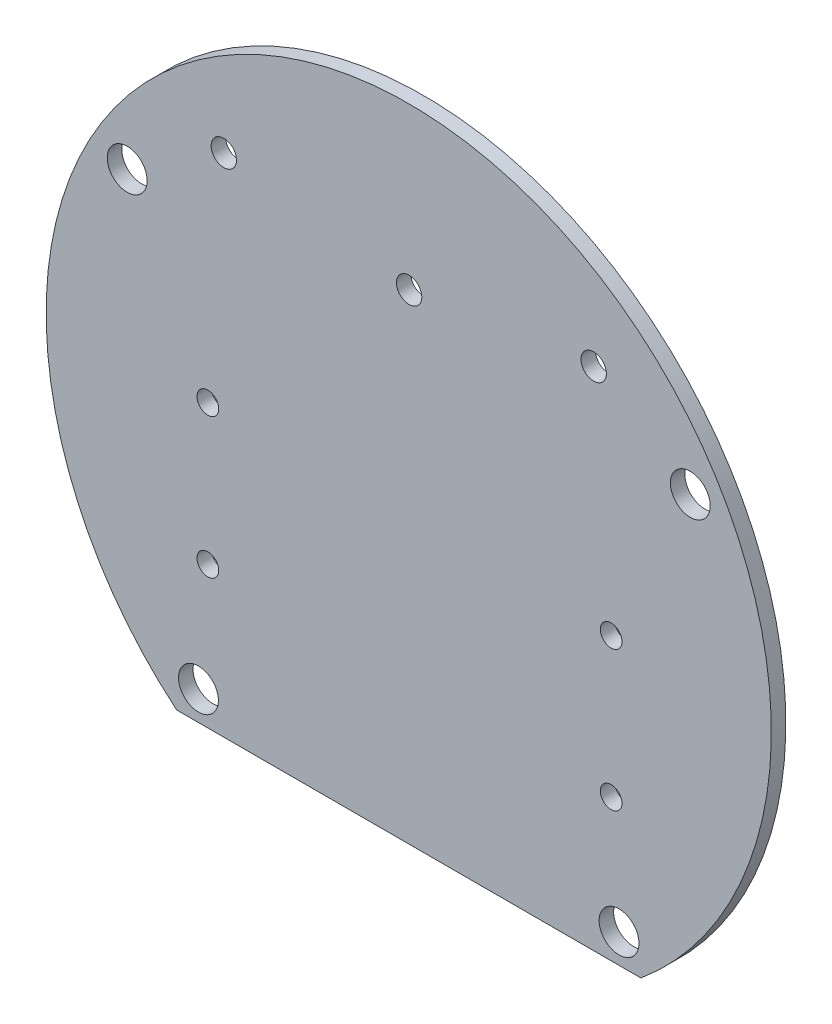
from build123d import *

# Parameters (mm, degrees)
ESBO_O1_R                  = 50
RESSALTO_EXTRUS_O1_DEPTH   = 2
ESBO_O2_R                  = 2.75
CORTE_EXTRUS_O1_DEPTH      = 2
CORTE_EXTRUS_O2_DEPTH      = 1
CORTE_EXTRUS_O2_DEPTH_BACK = 10
ESBO_O5_R                  = 1.5
ESBO_O5_R_2                = 1.75
CORTE_EXTRUS_O3_DEPTH      = 10


with BuildPart() as part:
    # Esboço1 → Ressalto-extrusão1 (new body)
    with BuildSketch(Plane.XY):
        Circle(ESBO_O1_R)
    extrude(amount=RESSALTO_EXTRUS_O1_DEPTH)

    # Esboço2 → Corte-extrusão1 (cut)
    with BuildSketch(Plane.XY.offset(2)):
        with Locations((-29, -34.409301068)):
            Circle(ESBO_O2_R)
        with Locations((29, -34.409301068)):
            Circle(ESBO_O2_R)
        with Locations((-38.824197531, 22.752619324)):
            Circle(ESBO_O2_R)
        with Locations((38.824197531, 22.752619324)):
            Circle(ESBO_O2_R)
    extrude(amount=-CORTE_EXTRUS_O1_DEPTH, mode=Mode.SUBTRACT)

    # Esboço4 → Corte-extrusão2 (cut, two sides)
    with BuildSketch(Plane.XY.offset(2)) as corte_extrus_o2_sk:
        Polygon((-40.723859979, -38.409301068), (44.57073926, -38.409301068), (1.923439641, -68.002213614), align=None)
    extrude(amount=CORTE_EXTRUS_O2_DEPTH, mode=Mode.SUBTRACT)
    extrude(corte_extrus_o2_sk.sketch, amount=-CORTE_EXTRUS_O2_DEPTH_BACK, mode=Mode.SUBTRACT)

    # Esboço5 → Corte-extrusão3 (cut)
    with BuildSketch(Plane(origin=(0, 0, 0), x_dir=(-1, 0, 0), z_dir=(0, 0, -1))):
        with Locations((-27.91, -18.86)):
            Circle(ESBO_O5_R)
        with Locations((27.7, -18.86)):
            Circle(ESBO_O5_R)
        with Locations((27.7, 0.44)):
            Circle(ESBO_O5_R)
        with Locations((-27.91, 0.44)):
            Circle(ESBO_O5_R)
        with Locations((25.5, 31.36)):
            Circle(ESBO_O5_R_2)
        with Locations((-0.05, 27.79)):
            Circle(ESBO_O5_R_2)
        with Locations((-25.5, 31.36)):
            Circle(ESBO_O5_R_2)
    extrude(amount=-CORTE_EXTRUS_O3_DEPTH, mode=Mode.SUBTRACT)


solid = part.part
